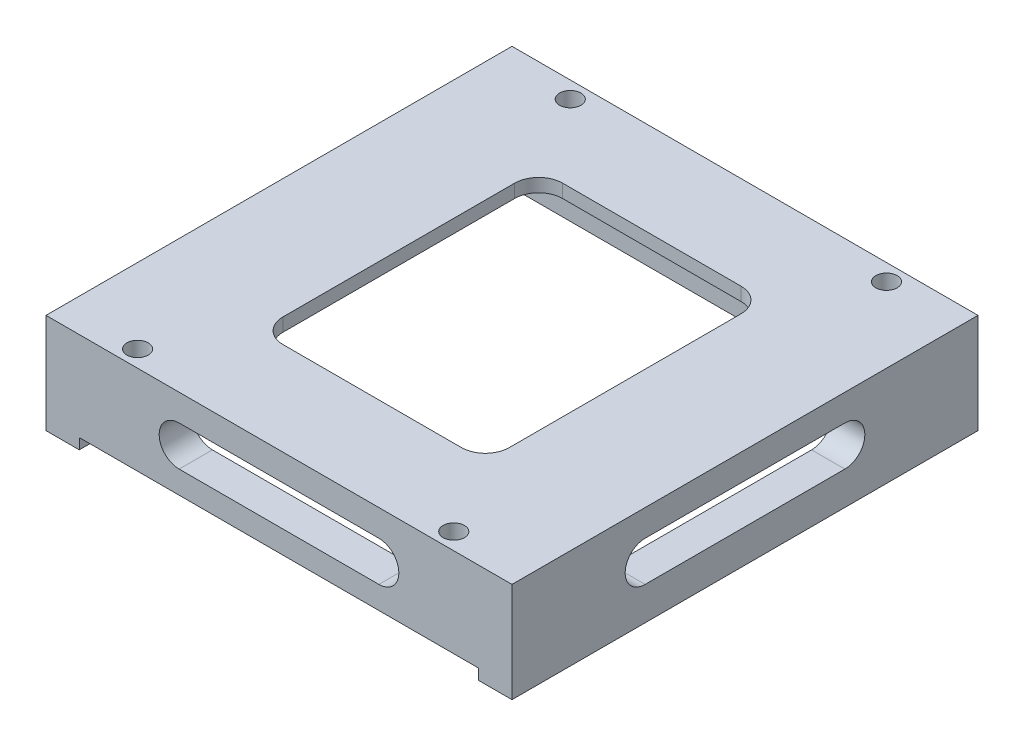
from build123d import *

# Parameters (mm, degrees)
SKETCH1_W           = 70
SKETCH1_H           = 70
SKETCH1_W_2         = 60
SKETCH1_H_2         = 60
BOSS_EXTRUDE1_DEPTH = 15
BOSS_EXTRUDE2_START = 15
SKETCH1_2_W         = 70
SKETCH1_2_H         = 70
BOSS_EXTRUDE2_DEPTH = 2
CUT_EXTRUDE1_DEPTH  = 53.5
CUT_EXTRUDE2_DEPTH  = 38.5
CUT_EXTRUDE3_START  = 13
SKETCH4_W           = 34
SKETCH4_H           = 42
CUT_EXTRUDE3_DEPTH  = 5
FILLET1_R           = 3.6
SKETCH5_R           = 1.6
CUT_EXTRUDE4_DEPTH  = 25
SKETCH7_W           = 60
SKETCH7_H           = 5
CUT_EXTRUDE5_DEPTH  = 1.6


with BuildPart() as part:
    # Sketch1 → Boss-Extrude1 (new body)
    with BuildSketch(Plane(origin=(0, 0, 0), x_dir=(1, 0, 0), z_dir=(0, 1, 0))):
        Rectangle(SKETCH1_W, SKETCH1_H)
        Rectangle(SKETCH1_W_2, SKETCH1_H_2, mode=Mode.SUBTRACT)
    extrude(amount=BOSS_EXTRUDE1_DEPTH)

    # Sketch1_2 → Boss-Extrude2 (add)
    with BuildSketch(Plane(origin=(0, 0, 0), x_dir=(1, 0, 0), z_dir=(0, 1, 0)).offset(BOSS_EXTRUDE2_START)):
        Rectangle(SKETCH1_2_W, SKETCH1_2_H)
    extrude(amount=-BOSS_EXTRUDE2_DEPTH)

    # Sketch2 → Cut-Extrude1 (cut, symmetric)
    with BuildSketch(Plane.XY):
        with BuildLine():
            Line((-15, 11), (15, 11))
            ThreePointArc((15, 11), (18, 8), (15, 5))
            Line((15, 5), (-15, 5))
            ThreePointArc((-15, 5), (-18, 8), (-15, 11))
        make_face()
    extrude(amount=CUT_EXTRUDE1_DEPTH, both=True, mode=Mode.SUBTRACT)

    # Sketch3 → Cut-Extrude2 (cut, symmetric)
    with BuildSketch(Plane(origin=(0, 0, 0), x_dir=(0, 0, -1), z_dir=(1, 0, 0))):
        with BuildLine():
            Line((15, 5), (-15, 5))
            ThreePointArc((-15, 5), (-18, 8), (-15, 11))
            Line((-15, 11), (15, 11))
            ThreePointArc((15, 11), (18, 8), (15, 5))
        make_face()
    extrude(amount=CUT_EXTRUDE2_DEPTH, both=True, mode=Mode.SUBTRACT)

    # Sketch4 → Cut-Extrude3 (cut)
    with BuildSketch(Plane(origin=(0, 0, 0), x_dir=(1, 0, 0), z_dir=(0, 1, 0)).offset(CUT_EXTRUDE3_START)):
        Rectangle(SKETCH4_W, SKETCH4_H)
    extrude(amount=CUT_EXTRUDE3_DEPTH, mode=Mode.SUBTRACT)

    # Fillet1
    fillet1_edges = [part.edges().sort_by_distance(p)[0] for p in [
        (17, 14, 21),
        (17, 14, -21),
        (-17, 14, -21),
        (-17, 14, 21),
    ]]
    fillet(fillet1_edges, radius=FILLET1_R)

    # Sketch5 → Cut-Extrude4 (cut)
    with BuildSketch(Plane(origin=(0, 0, 0), x_dir=(1, 0, 0), z_dir=(0, 1, 0))):
        with Locations((-23.75, 32.5)):
            Circle(SKETCH5_R)
        with Locations((-23.75, -32.5)):
            Circle(SKETCH5_R)
        with Locations((23.75, 32.5)):
            Circle(SKETCH5_R)
        with Locations((23.75, -32.5)):
            Circle(SKETCH5_R)
    extrude(amount=CUT_EXTRUDE4_DEPTH, mode=Mode.SUBTRACT)

    # Sketch7 → Cut-Extrude5 (cut)
    with BuildSketch(Plane(origin=(0, 0, 0), x_dir=(1, 0, 0), z_dir=(0, 1, 0))):
        with Locations((0, 32.5)):
            Rectangle(SKETCH7_W, SKETCH7_H)
        with Locations((0, -32.5)):
            Rectangle(SKETCH7_W, SKETCH7_H)
    extrude(amount=CUT_EXTRUDE5_DEPTH, mode=Mode.SUBTRACT)


solid = part.part
